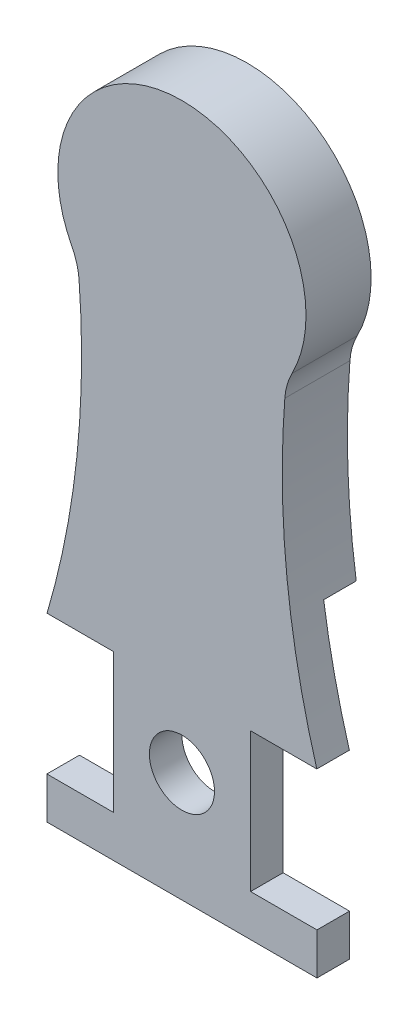
from build123d import *

# Parameters (mm, degrees)
BODY_DEPTH            = 10
SKETCH2_R             = 5
ATTACHMENT_HOLE_DEPTH = 11
CUT_EXTRUDE28_DEPTH   = 11
CUT_EXTRUDE30_DEPTH   = 5
FILLET1_R             = 10
FILLET2_R             = 10


with BuildPart() as part:
    # Sketch1 → Body (new body)
    with BuildSketch(Plane.XY):
        with BuildLine():
            ThreePointArc((-57.453333234, -48.209070726), (-24.034507314, 1.033281591), (-16, 60))
            ThreePointArc((-16, 60), (0, 89.414069015), (16, 60))
            ThreePointArc((16, 60), (24.034507314, 1.033281591), (57.453333234, -48.209070726))
            ThreePointArc((57.453333234, -48.209070726), (0, -75), (-57.453333234, -48.209070726))
        make_face()
    extrude(amount=BODY_DEPTH)

    # Sketch2 → Attachment Hole (cut, through all)
    with BuildSketch(Plane.XY.offset(10)):
        Circle(SKETCH2_R)
    extrude(amount=-ATTACHMENT_HOLE_DEPTH, mode=Mode.SUBTRACT)

    # Sketch34 → Cut-Extrude28 (cut, through all)
    with BuildSketch(Plane.XY.offset(10)):
        with BuildLine():
            Line((-20.993197074, 10.845815), (-10.542895, 10.845815))
            Line((-10.542895, 10.845815), (-10.542895, -10.542895))
            Line((-10.542895, -10.542895), (-20.741205, -10.542895))
            Line((-20.741205, -10.542895), (-20.741205, -16.942445))
            Line((-20.741205, -16.942445), (20.741205, -16.942445))
            Line((20.741205, -16.942445), (20.741205, -10.542895))
            Line((20.741205, -10.542895), (10.542895, -10.542895))
            Line((10.542895, -10.542895), (10.542895, 10.845815))
            Line((10.542895, 10.845815), (20.993197074, 10.845815))
            ThreePointArc((20.993197074, 10.845815), (36.689111405, -20.246199356), (57.453333234, -48.209070726))
            ThreePointArc((57.453333234, -48.209070726), (0, -75), (-57.453333234, -48.209070726))
            ThreePointArc((-57.453333234, -48.209070726), (-35.302517172, -21.102274411), (-20.993197074, 10.845815))
        make_face()
    extrude(amount=-CUT_EXTRUDE28_DEPTH, mode=Mode.SUBTRACT)

    # Sketch35 → Cut-Extrude30 (cut)
    with BuildSketch(Plane(origin=(0, 0, 0), x_dir=(-1, 0, 0), z_dir=(0, 0, -1))):
        with BuildLine():
            Line((20.993197074, 10.845815), (10.542895, 10.845815))
            Line((10.542895, 10.845815), (10.542895, -10.542895))
            Line((10.542895, -10.542895), (20.741205, -10.542895))
            Line((20.741205, -10.542895), (20.741205, -16.942445))
            Line((20.741205, -16.942445), (-20.741205, -16.942445))
            Line((-20.741205, -16.942445), (-20.741205, -10.542895))
            Line((-20.741205, -10.542895), (-10.542895, -10.542895))
            Line((-10.542895, -10.542895), (-10.542895, 10.845815))
            Line((-10.542895, 10.845815), (-20.993197074, 10.845815))
            ThreePointArc((-20.993197074, 10.845815), (-18.675130989, 19.753520203), (-16.85963199, 28.777078577))
            ThreePointArc((-16.85963199, 28.777078577), (0, 36.631345), (16.85963199, 28.777078577))
            ThreePointArc((16.85963199, 28.777078577), (18.631142052, 19.74337975), (20.993197074, 10.845815))
        make_face()
    extrude(amount=-CUT_EXTRUDE30_DEPTH, mode=Mode.SUBTRACT)

    # Fillet1
    fillet1_edges = [part.edges().sort_by_distance(p)[0] for p in [
        (16, 60, 5),
    ]]
    fillet(fillet1_edges, radius=FILLET1_R)

    # Fillet2
    fillet2_edges = [part.edges().sort_by_distance(p)[0] for p in [
        (-16, 60, 5),
    ]]
    fillet(fillet2_edges, radius=FILLET2_R)


solid = part.part
